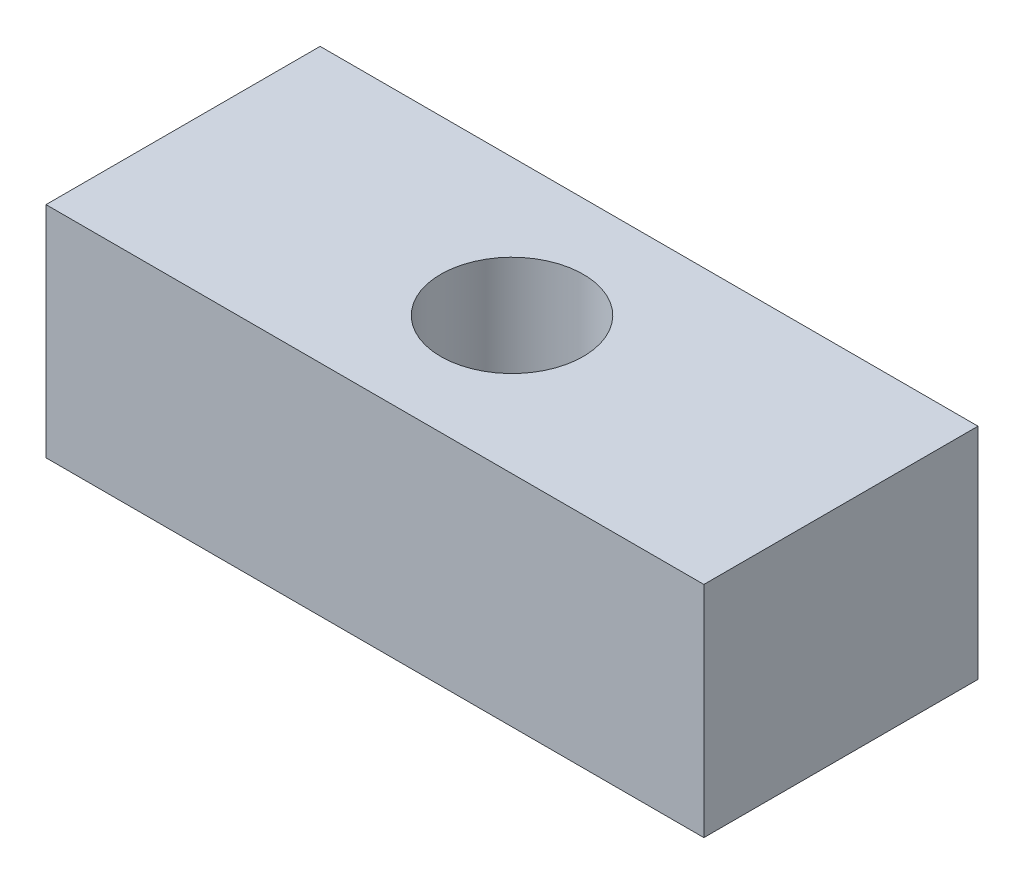
from build123d import *

# Parameters (mm, degrees)
CROQUIS1_W              = 60
CROQUIS1_H              = 20
SALIENTE_EXTRUIR1_DEPTH = 25
CROQUIS2_R              = 6.5
CORTAR_EXTRUIR1_DEPTH   = 20


with BuildPart() as part:
    # Croquis1 → Saliente-Extruir1 (new body)
    with BuildSketch(Plane.XY):
        Rectangle(CROQUIS1_W, CROQUIS1_H)
    extrude(amount=SALIENTE_EXTRUIR1_DEPTH)

    # Croquis2 → Cortar-Extruir1 (cut)
    with BuildSketch(Plane(origin=(0, 10, 0), x_dir=(1, 0, 0), z_dir=(0, 1, 0))):
        with Locations((0, -12.5)):
            Circle(CROQUIS2_R)
    extrude(amount=-CORTAR_EXTRUIR1_DEPTH, mode=Mode.SUBTRACT)


solid = part.part
